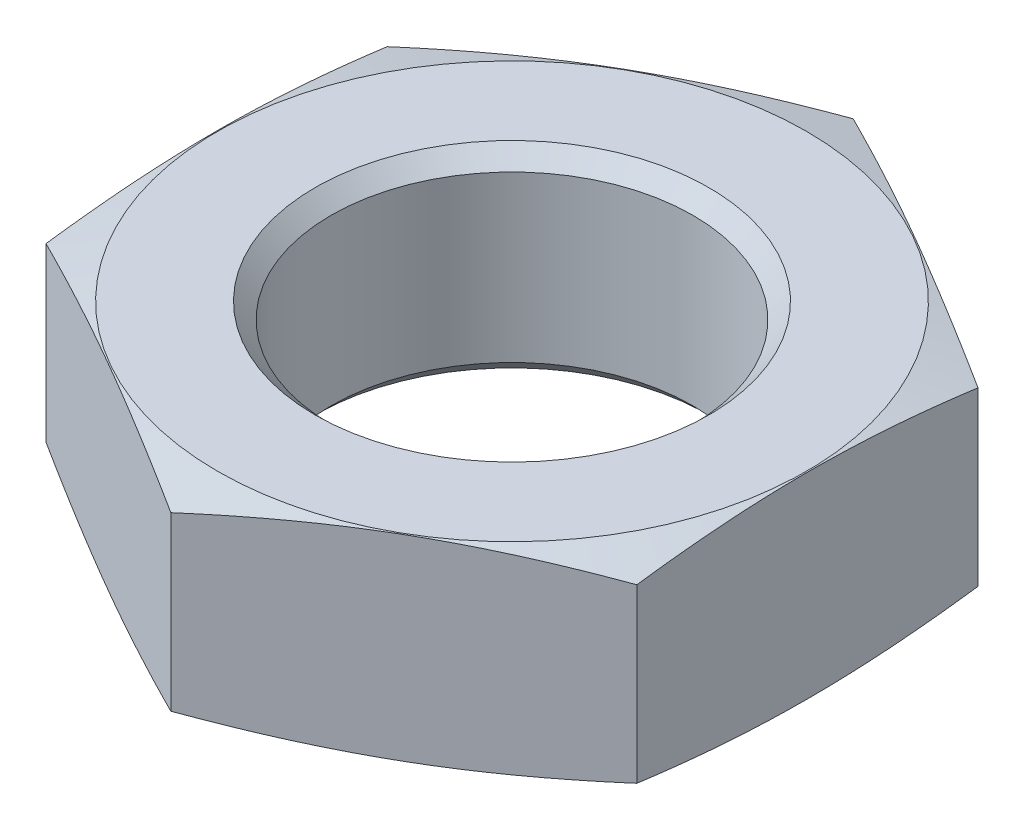
from build123d import *

# Parameters (mm, degrees)
CUT_EXTRUDE1_DEPTH      = 11
CUT_EXTRUDE1_DEPTH_BACK = 11
SKETCH2_W               = 120
SKETCH2_H               = 120


with BuildPart() as part:
    # Sketch1 → Revolve1 (revolve)
    with BuildSketch(Plane.XY):
        Polygon((0, 0), (14.95, 0), (33.610254038, -5), (14.95, -10), (0, -10), align=None)
    revolve(axis=Axis((0, -10, 0), (0, 1, 0)))

    # Sketch2 → Cut-Extrude1 (cut, two sides: drawn at the far end of the back side and taken through both)
    with BuildSketch(Plane(origin=(0, 0, 0), x_dir=(1, 0, 0), z_dir=(0, 1, 0)).offset(-CUT_EXTRUDE1_DEPTH_BACK)):
        Rectangle(SKETCH2_W, SKETCH2_H)
        Polygon((-15, -8.660254038), (0, -17.320508076), (15, -8.660254038), (15, 8.660254038), (0, 17.320508076), (-15, 8.660254038), align=None, mode=Mode.SUBTRACT)
    extrude(amount=CUT_EXTRUDE1_DEPTH + CUT_EXTRUDE1_DEPTH_BACK, mode=Mode.SUBTRACT)

    # Sketch3 → Cut-Revolve1 (revolve, cut)
    with BuildSketch(Plane.XY):
        Polygon((0, 0), (10, 0), (9.188, -0.812), (9.188, -9.188), (10, -10), (0, -10), align=None)
    revolve(axis=Axis((0, -10, 0), (0, 1, 0)), mode=Mode.SUBTRACT)


solid = part.part
